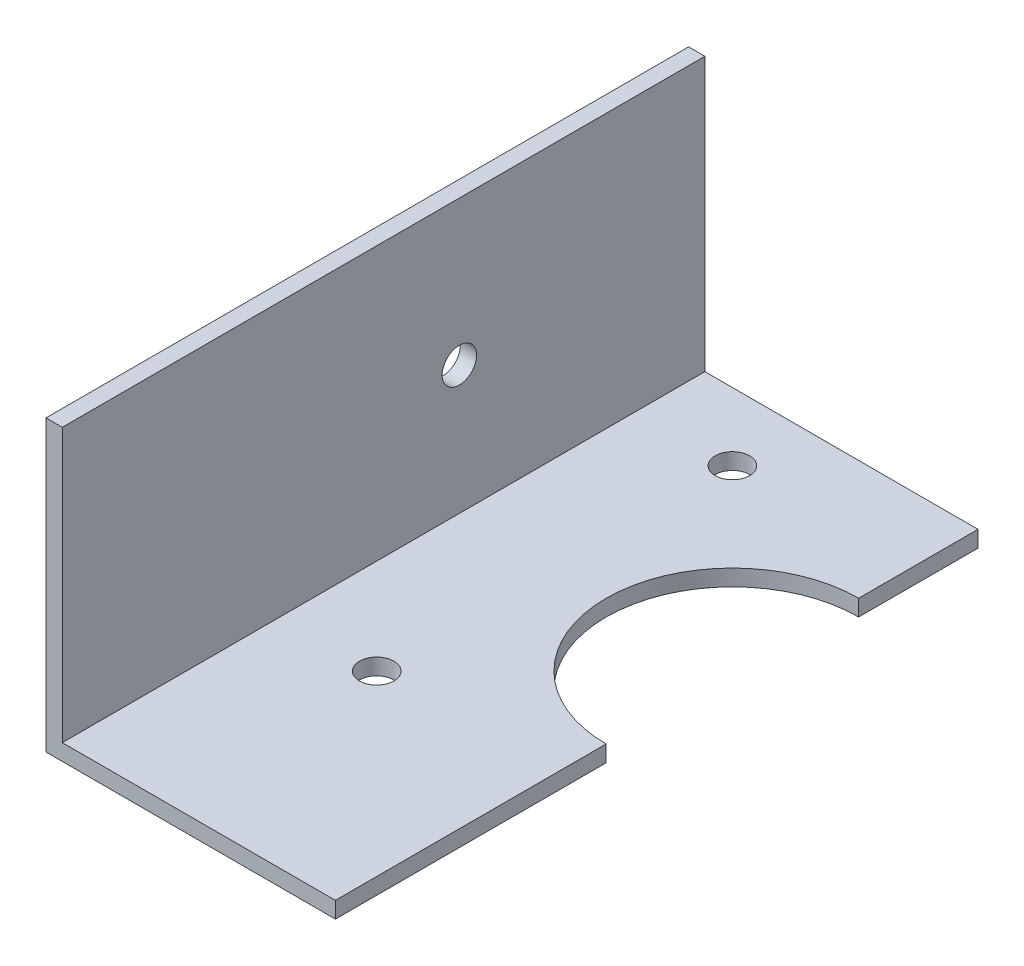
from build123d import *

# Parameters (mm, degrees)
EXTRUDE1_DEPTH     = 56
SKETCH2_R          = 1.5
CUT_EXTRUDE1_DEPTH = 26.22
SKETCH3_R          = 11
CUT_EXTRUDE2_DEPTH = 26.22
SKETCH4_R          = 1.5
CUT_EXTRUDE3_DEPTH = 26.22
SKETCH5_R          = 1.5
CUT_EXTRUDE4_DEPTH = 26.22


with BuildPart() as part:
    # Sketch1 → Extrude1 (new body)
    with BuildSketch(Plane.XY):
        Polygon((0, 0), (0, -25.22), (25.22, -25.22), (25.22, -23.8), (1.42, -23.8), (1.42, 0), align=None)
    extrude(amount=EXTRUDE1_DEPTH)

    # Sketch2 → Cut-Extrude1 (cut, through all)
    with BuildSketch(Plane.ZY):
        with Locations((21.4, -12.61)):
            Circle(SKETCH2_R)
    extrude(amount=-CUT_EXTRUDE1_DEPTH, mode=Mode.SUBTRACT)

    # Sketch3 → Cut-Extrude2 (cut, through all)
    with BuildSketch(Plane.XZ.offset(25.22)):
        with Locations((25.22, 21.4)):
            Circle(SKETCH3_R)
    extrude(amount=-CUT_EXTRUDE2_DEPTH, mode=Mode.SUBTRACT)

    # Sketch4 → Cut-Extrude3 (cut, through all)
    with BuildSketch(Plane.XZ.offset(25.22)):
        with Locations((9.72, 36.9)):
            Circle(SKETCH4_R)
    extrude(amount=-CUT_EXTRUDE3_DEPTH, mode=Mode.SUBTRACT)

    # Sketch5 → Cut-Extrude4 (cut, through all)
    with BuildSketch(Plane.XZ.offset(25.22)):
        with Locations((9.72, 5.9)):
            Circle(SKETCH5_R)
    extrude(amount=-CUT_EXTRUDE4_DEPTH, mode=Mode.SUBTRACT)


solid = part.part
